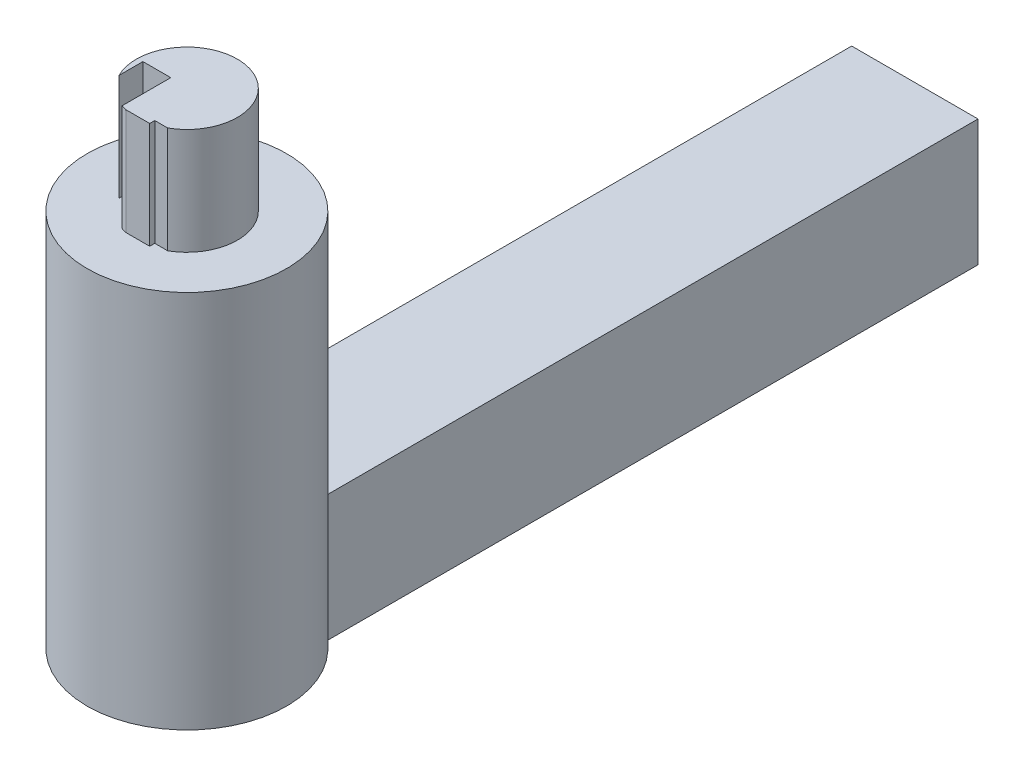
from build123d import *

# Parameters (mm, degrees)
SKETCH1_W                = 9.5
SKETCH1_H                = 54.75
BOSS_EXTRUDE1_DEPTH      = 9.5
SKETCH2_R                = 7.5
BOSS_EXTRUDE2_DEPTH      = 19
BOSS_EXTRUDE2_DEPTH_BACK = 9.5
BOSS_EXTRUDE3_DEPTH      = 8


with BuildPart() as part:
    # Sketch1 → Boss-Extrude1 (new body)
    with BuildSketch(Plane(origin=(0, 0, 0), x_dir=(1, 0, 0), z_dir=(0, 1, 0))):
        Rectangle(SKETCH1_W, SKETCH1_H)
    extrude(amount=BOSS_EXTRUDE1_DEPTH)

    # Sketch2 → Boss-Extrude2 (add, two sides)
    with BuildSketch(Plane(origin=(0, 9.5, 0), x_dir=(1, 0, 0), z_dir=(0, 1, 0))) as boss_extrude2_sk:
        with Locations((0, -27.375)):
            Circle(SKETCH2_R)
    extrude(amount=BOSS_EXTRUDE2_DEPTH)
    extrude(boss_extrude2_sk.sketch, amount=-BOSS_EXTRUDE2_DEPTH_BACK)

    # Sketch3 → Boss-Extrude3 (add)
    with BuildSketch(Plane(origin=(0, 28.5, 0), x_dir=(1, 0, 0), z_dir=(0, 1, 0))):
        with BuildLine():
            Line((-1.29624151, -30.947080339), (-1.29624151, -27.289433429))
            Line((-1.29624151, -27.289433429), (-3.391270856, -27.289433429))
            Line((-3.391270856, -27.289433429), (-3.391270856, -29.089433429))
            ThreePointArc((-3.391270856, -29.089433429), (1.102654775, -23.738497223), (1.86802767, -30.684149834))
            Line((1.86802767, -30.684149834), (0.894110574, -30.684149834))
            Line((0.894110574, -30.684149834), (0.894110574, -31.065442297))
            Line((0.894110574, -31.065442297), (-0.905889426, -31.065442297))
            ThreePointArc((-0.905889426, -31.065442297), (-1.102654775, -31.011502777), (-1.29624151, -30.947080339))
        make_face()
    extrude(amount=BOSS_EXTRUDE3_DEPTH)


solid = part.part
